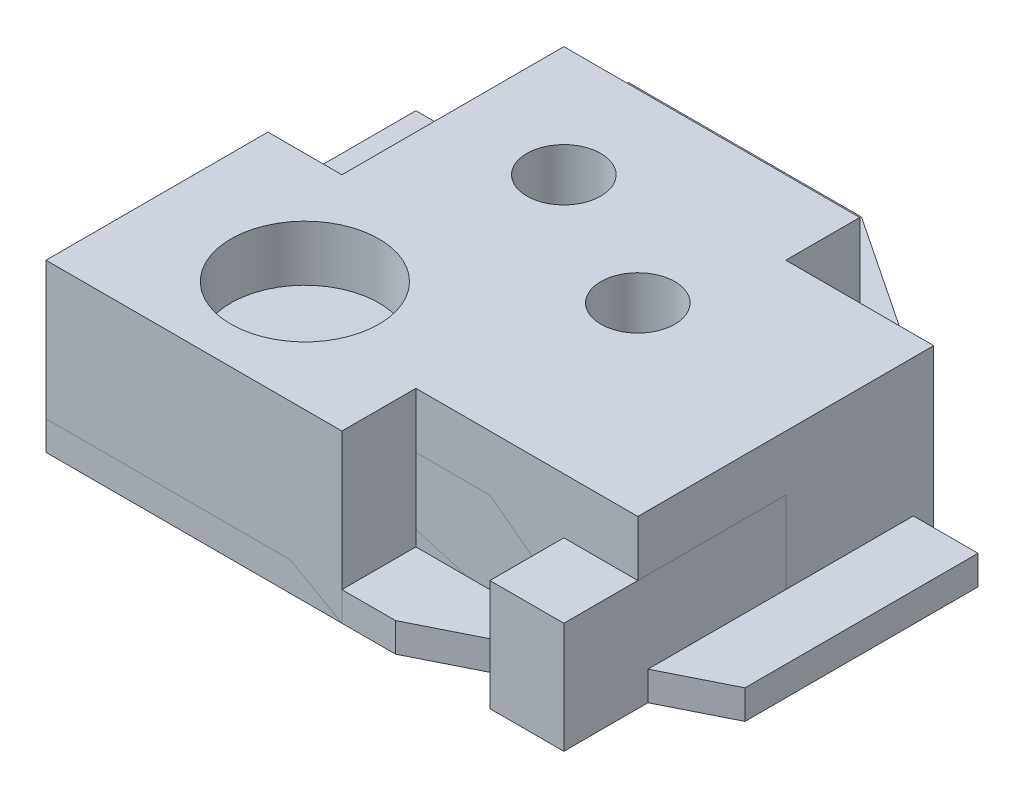
from build123d import *

# Parameters (mm, degrees)
SKETCH2_R           = 6.35
BOSS_EXTRUDE1_DEPTH = 19.05
SKETCH3_R           = 12.7
SKETCH3_R_2         = 6.35
BOSS_EXTRUDE2_DEPTH = 28.575
SKETCH5_R           = 10
BOSS_EXTRUDE3_DEPTH = 5


with BuildPart() as part:
    # Sketch2 → Boss-Extrude1 (new body)
    with BuildSketch(Plane(origin=(0, 0, 0), x_dir=(1, 0, 0), z_dir=(0, 1, 0))):
        Polygon((0, 0), (0, 63.5), (50.8, 63.5), (88.9, 38.1), (88.9, 0), (76.2, 0), (76.2, 12.7), (12.7, 12.7), (12.7, 0), align=None)
        with Locations((25.4, 38.1)):
            Circle(SKETCH2_R, mode=Mode.SUBTRACT)
        with Locations((57.15, 38.1)):
            Circle(SKETCH2_R, mode=Mode.SUBTRACT)
    extrude(amount=BOSS_EXTRUDE1_DEPTH)


with BuildPart() as body_2:
    # Sketch3 → Boss-Extrude2 (new body)
    with BuildSketch(Plane(origin=(0, 0, 0), x_dir=(1, 0, 0), z_dir=(0, 1, 0))):
        Polygon((0, 0), (0, 38.1), (12.7, 38.1), (12.7, 76.2), (63.5, 76.2), (63.5, 63.5), (88.9, 63.5), (88.9, 12.7), (50.8, 12.7), (50.8, 0), align=None)
        with Locations((25.4, 19.05)):
            Circle(SKETCH3_R, mode=Mode.SUBTRACT)
        with Locations((31.75, 57.15)):
            Circle(SKETCH3_R_2, mode=Mode.SUBTRACT)
        with Locations((57.15, 44.45)):
            Circle(SKETCH3_R_2, mode=Mode.SUBTRACT)
    extrude(amount=BOSS_EXTRUDE2_DEPTH)


with BuildPart() as body_3:
    # Sketch5 → Boss-Extrude3 (new body)
    with BuildSketch(Plane(origin=(0, 0, 0), x_dir=(1, 0, 0), z_dir=(0, 1, 0))):
        Polygon((0, 0), (0, 100), (40, 100), (70, 80), (70, 60), (100, 60), (100, 20), (60, 0), align=None)
        with Locations((20, 80)):
            Circle(SKETCH5_R, mode=Mode.SUBTRACT)
        with Locations((20, 20)):
            Circle(SKETCH5_R, mode=Mode.SUBTRACT)
        with Locations((75, 30)):
            Circle(SKETCH5_R, mode=Mode.SUBTRACT)
    extrude(amount=BOSS_EXTRUDE3_DEPTH)


solid = Compound([part.part, body_2.part, body_3.part])
